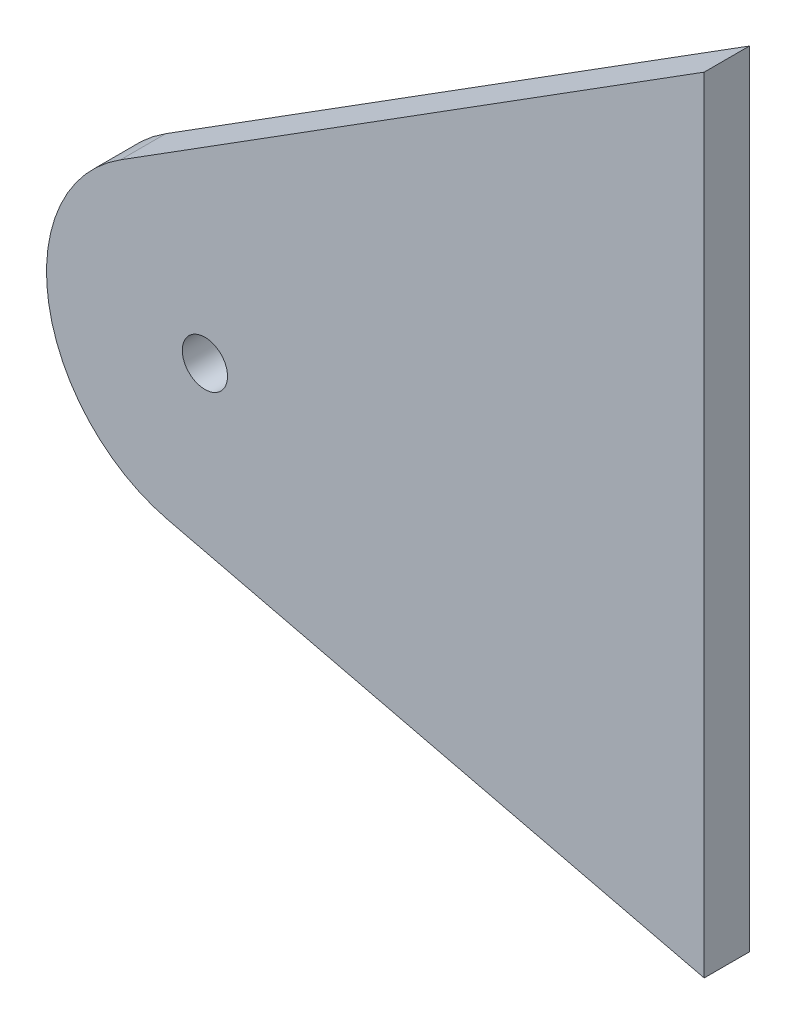
from build123d import *

# Parameters (mm, degrees)
MODEL_R                 = 1.500000302
SALIENTE_EXTRUIR1_DEPTH = 3


with BuildPart() as part:
    # Model → Saliente-Extruir1 (new body)
    with BuildSketch(Plane.XY):
        with BuildLine():
            Line((33.092598302, 20.364675113), (33.092598302, 33.261670113))
            Line((33.092598302, 33.261670113), (-5.597442698, 8.883616113))
            ThreePointArc((-5.597442698, 8.883616113), (-10.360174651, -1.707858659), (-2.449856698, -10.210200887))
            Line((-2.449856698, -10.210200887), (33.092598302, -18.738329887))
            Line((33.092598302, -18.738329887), (33.092598302, 20.364675113))
        make_face()
        Circle(MODEL_R, mode=Mode.SUBTRACT)
    extrude(amount=SALIENTE_EXTRUIR1_DEPTH)


solid = part.part
